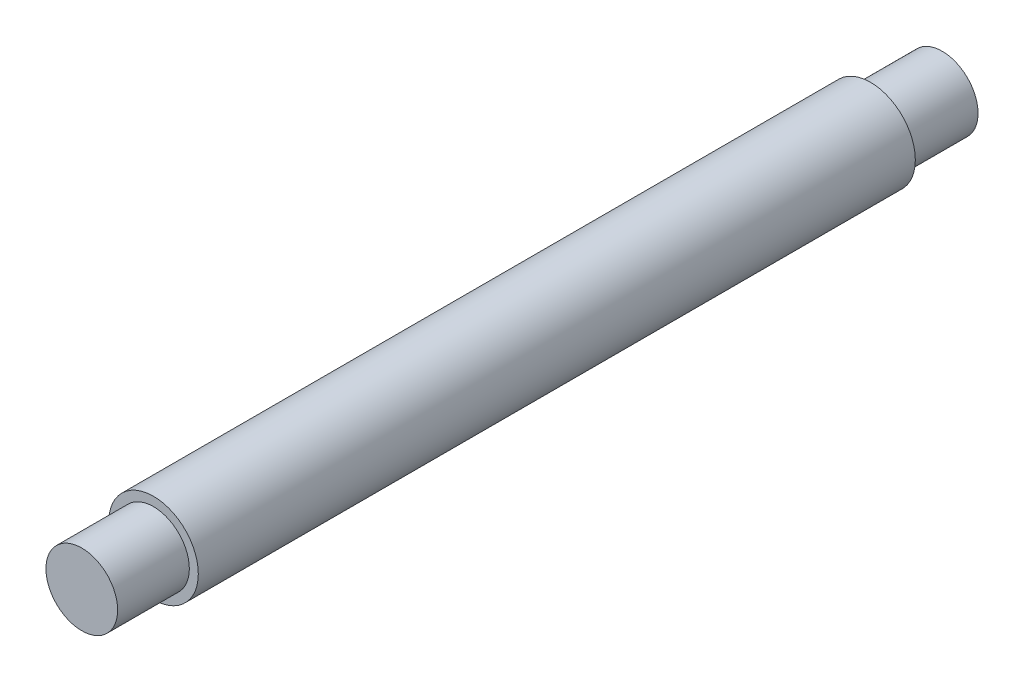
from build123d import *

# Parameters (mm, degrees)
SKETCH1_R            = 6.35
BOSS_EXTRUDE2_DEPTH  = 101.6
SKETCH5_R            = 5.08
BOSS_EXTRUDE14_DEPTH = 10.16
SKETCH9_R            = 5.08
BOSS_EXTRUDE15_DEPTH = 10.16


with BuildPart() as part:
    # Sketch1 → Boss-Extrude2 (new body)
    with BuildSketch(Plane.XY):
        with Locations((-5.49342359, 5.704709113)):
            Circle(SKETCH1_R)
    extrude(amount=BOSS_EXTRUDE2_DEPTH)

    # Sketch5 → Boss-Extrude14 (add)
    with BuildSketch(Plane.XY.offset(101.6)):
        with Locations((-5.49342359, 5.704709113)):
            Circle(SKETCH5_R)
    extrude(amount=BOSS_EXTRUDE14_DEPTH)

    # Sketch9 → Boss-Extrude15 (add)
    with BuildSketch(Plane(origin=(0, 0, 0), x_dir=(-1, 0, 0), z_dir=(0, 0, -1))):
        with Locations((5.49342359, 5.704709113)):
            Circle(SKETCH9_R)
    extrude(amount=BOSS_EXTRUDE15_DEPTH)


solid = part.part
